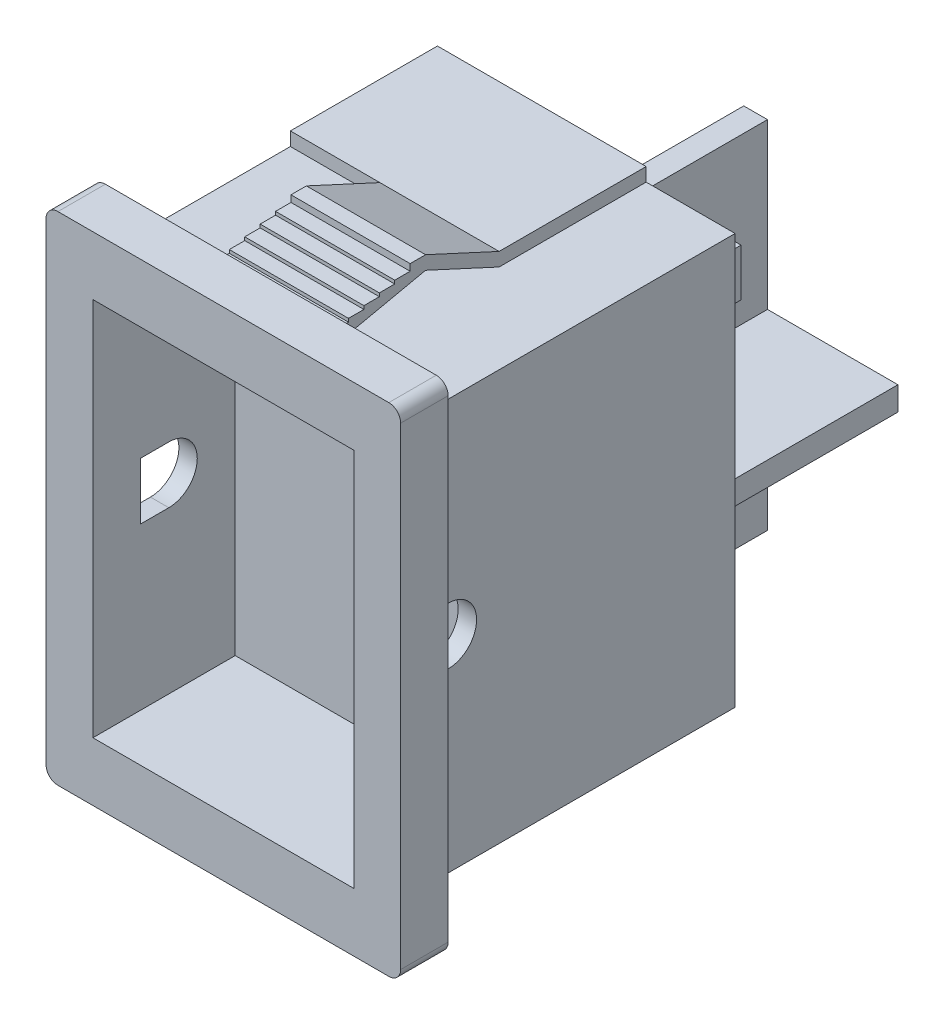
from build123d import *

# Parameters (mm, degrees)
SKETCH1_W                = 14.95
SKETCH1_H                = 20.95
SKETCH1_W_2              = 11
SKETCH1_H_2              = 16
BOSS_EXTRUDE1_DEPTH      = 2
SKETCH2_W                = 12.55
SKETCH2_H                = 17.3
BOSS_EXTRUDE2_DEPTH      = 13.3
SKETCH3_W                = 6.2
SKETCH3_H                = 18.44
BOSS_EXTRUDE3_DEPTH      = 8.8
BOSS_EXTRUDE4_DEPTH      = 2.525
BOSS_EXTRUDE4_DEPTH_BACK = 2.5
BOSS_EXTRUDE5_DEPTH      = 7.14
SKETCH6_W                = 2.5
SKETCH6_H                = 2
BOSS_EXTRUDE6_DEPTH      = 1
CUT_EXTRUDE1_DEPTH       = 12.55
SKETCH8_W                = 11
SKETCH8_H                = 16
CUT_EXTRUDE2_DEPTH       = 4
FILLET1_R                = 0.5


with BuildPart() as part:
    # Sketch1 → Boss-Extrude1 (new body)
    with BuildSketch(Plane.XY):
        Rectangle(SKETCH1_W, SKETCH1_H)
        Rectangle(SKETCH1_W_2, SKETCH1_H_2, mode=Mode.SUBTRACT)
    extrude(amount=BOSS_EXTRUDE1_DEPTH)

    # Sketch2 → Boss-Extrude2 (add)
    with BuildSketch(Plane(origin=(0, 0, 0), x_dir=(-1, 0, 0), z_dir=(0, 0, -1))):
        Rectangle(SKETCH2_W, SKETCH2_H)
    extrude(amount=BOSS_EXTRUDE2_DEPTH)

    # Sketch3 → Boss-Extrude3 (add)
    with BuildSketch(Plane.ZY.offset(6.275)):
        with Locations((-10.2, 0)):
            Rectangle(SKETCH3_W, SKETCH3_H)
    extrude(amount=-BOSS_EXTRUDE3_DEPTH)

    # Sketch4 → Boss-Extrude4 (add, two sides)
    with BuildSketch(Plane(origin=(0, 0, 0), x_dir=(0, 0, -1), z_dir=(1, 0, 0))) as boss_extrude4_sk:
        Polygon((7.1, -9.22), (4, -10.65), (3.35, -10.65), (3.35, -10.3705), (2.7, -10.3705), (2.7, -10.23075), (2.05, -10.23075), (2.05, -10.091), (1.4, -10.091), (1.4, -9.95125), (0.75, -9.95125), (0.75, -9.8115), (0, -9.8115), (0, -9.22), (4, -10.08), (7.1, -8.65), align=None)
        Polygon((7.1, 9.22), (7.1, 8.65), (4, 10.08), (0, 9.22), (0, 9.8115), (0.75, 9.8115), (0.75, 9.95125), (1.4, 9.95125), (1.4, 10.091), (2.05, 10.091), (2.05, 10.23075), (2.7, 10.23075), (2.7, 10.3705), (3.35, 10.3705), (3.35, 10.65), (4, 10.65), align=None)
    extrude(amount=BOSS_EXTRUDE4_DEPTH)
    extrude(boss_extrude4_sk.sketch, amount=-BOSS_EXTRUDE4_DEPTH_BACK)

    # Sketch5 → Boss-Extrude5 (add)
    with BuildSketch(Plane(origin=(0, 0, -13.3), x_dir=(-1, 0, 0), z_dir=(0, 0, -1))):
        Polygon((0.5, 6.35), (-0.5, 6.35), (-0.5, -0.58), (-6, -0.58), (-6, -1.58), (-0.5, -1.58), (-0.5, -8.65), (0.5, -8.65), (0.5, -1.58), (6, -1.58), (6, -0.58), (0.5, -0.58), align=None)
    extrude(amount=BOSS_EXTRUDE5_DEPTH)

    # Sketch6 → Boss-Extrude6 (add)
    with BuildSketch(Plane(origin=(0, 0, -13.3), x_dir=(-1, 0, 0), z_dir=(0, 0, -1))):
        with Locations((2.232930788, -2.58)):
            Rectangle(SKETCH6_W, SKETCH6_H)
        with Locations((2.232930788, -7.58)):
            Rectangle(SKETCH6_W, SKETCH6_H)
        with Locations((-2.232930788, -7.58)):
            Rectangle(SKETCH6_W, SKETCH6_H)
        with Locations((-2.232930788, -2.58)):
            Rectangle(SKETCH6_W, SKETCH6_H)
        with Locations((4.275, 6.35)):
            Rectangle(SKETCH6_W, SKETCH6_H)
        with Locations((-4.275, 6.35)):
            Rectangle(SKETCH6_W, SKETCH6_H)
    extrude(amount=BOSS_EXTRUDE6_DEPTH)

    # Sketch7 → Cut-Extrude1 (cut)
    with BuildSketch(Plane(origin=(6.275, 0, 0), x_dir=(0, 0, -1), z_dir=(1, 0, 0))):
        with BuildLine():
            Line((1.2, 1.2), (0, 1.2))
            Line((0, 1.2), (0, -1.2))
            Line((0, -1.2), (1.2, -1.2))
            ThreePointArc((1.2, -1.2), (2.4, 0), (1.2, 1.2))
        make_face()
    extrude(amount=-CUT_EXTRUDE1_DEPTH, mode=Mode.SUBTRACT)

    # Sketch8 → Cut-Extrude2 (cut)
    with BuildSketch(Plane.XY):
        Rectangle(SKETCH8_W, SKETCH8_H)
    extrude(amount=-CUT_EXTRUDE2_DEPTH, mode=Mode.SUBTRACT)

    # Fillet1
    fillet1_edges = [part.edges().sort_by_distance(p)[0] for p in [
        (-7.475, 10.475, 1),
        (7.475, 10.475, 1),
        (7.475, -10.475, 1),
        (-7.475, -10.475, 1),
    ]]
    fillet(fillet1_edges, radius=FILLET1_R)


solid = part.part
